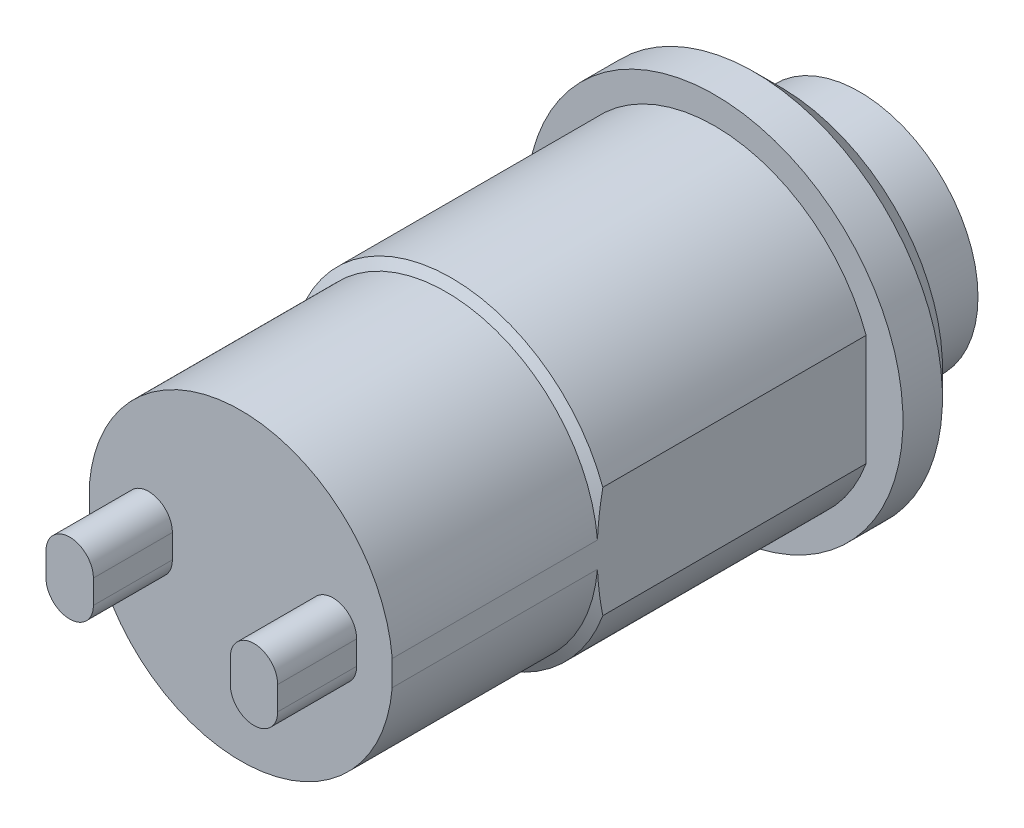
from build123d import *

# Parameters (mm, degrees)
BOSS_EXTRUDE1_DEPTH = 3
CUT_EXTRUDE1_DEPTH  = 18


with BuildPart() as part:
    # Sketch1 → Revolve1 (revolve)
    with BuildSketch(Plane(origin=(0, 0, 0), x_dir=(1, 0, 0), z_dir=(0, 1, 0))):
        with BuildLine():
            Line((7.15, 0), (6.125, 0))
            Line((6.125, 0), (6.125, -10))
            Line((6.125, -10), (5.77, -10.204959346))
            Line((5.77, -10.204959346), (5.77, -18))
            Line((5.77, -18), (0, -18))
            Line((0, -18), (0, 6.1))
            ThreePointArc((0, 6.1), (2.269911893, 5.949339194), (4.5, 5.5))
            Line((4.5, 5.5), (4.5, 2.5))
            Line((4.5, 2.5), (6.15, 2.5))
            Line((6.15, 2.5), (7.15, 1.5))
            Line((7.15, 1.5), (7.15, 0))
        make_face()
    revolve(axis=Axis((0, 0, -49.656832942), (0, 0, 1)))

    # Sketch2 → Boss-Extrude1 (add)
    with BuildSketch(Plane.XY.offset(18)):
        with BuildLine():
            Line((2.6, -0.45), (2.6, 0.45))
            ThreePointArc((2.6, 0.45), (3.5, 1.35), (4.4, 0.45))
            Line((4.4, 0.45), (4.4, -0.45))
            ThreePointArc((4.4, -0.45), (3.5, -1.35), (2.6, -0.45))
        make_face()
    boss_extrude1 = extrude(amount=BOSS_EXTRUDE1_DEPTH)

    # Mirror1: Boss-Extrude1 across plane
    add(boss_extrude1.mirror(Plane(origin=(0, 0, 0), x_dir=(0, 0, 1), z_dir=(1, 0, 0))))

    # Sketch3 → Cut-Extrude1 (cut)
    with BuildSketch(Plane.XY.offset(18)):
        with BuildLine():
            Line((5.75, 2.110242877), (5.75, -2.110242877))
            ThreePointArc((5.75, -2.110242877), (6.125, 0), (5.75, 2.110242877))
        make_face()
        with BuildLine():
            Line((-5.75, 2.110242877), (-5.75, -2.110242877))
            ThreePointArc((-5.75, -2.110242877), (-6.125, 0), (-5.75, 2.110242877))
        make_face()
    extrude(amount=-CUT_EXTRUDE1_DEPTH, mode=Mode.SUBTRACT)


solid = part.part
